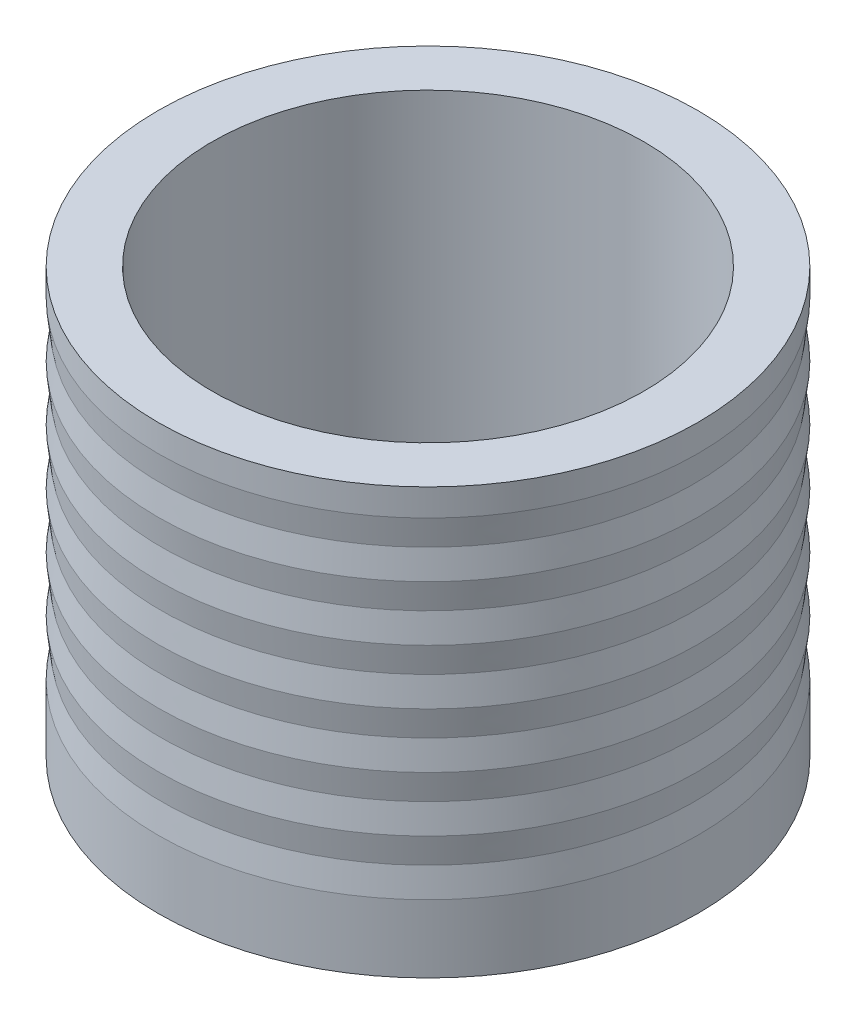
from build123d import *

# Parameters (mm, degrees)
SKETCH2_W       = 6.35
SKETCH2_H       = 50.00625
LPATTERN1_COUNT = 6
LPATTERN1_PITCH = 6.477


with BuildPart() as part:
    # Sketch2 → Revolve1 (revolve)
    with BuildSketch(Plane.XY):
        with Locations((28.575, 25.003125)):
            Rectangle(SKETCH2_W, SKETCH2_H)
    revolve(axis=Axis((0, -40.656569806, 0), (0, 1, 0)))

    # Sketch3 → Cut-Revolve1 (revolve, cut)
    with BuildSketch(Plane.XY):
        Polygon((31.75, 46.83125), (31.369, 43.59275), (31.75, 40.35425), align=None)
    cut_revolve1 = revolve(axis=Axis((0, -40.656569806, 0), (0, 1, 0)), mode=Mode.SUBTRACT)

    # LPattern1: Cut-Revolve1 ×6
    with Locations(*[(0, -i * LPATTERN1_PITCH, 0) for i in range(1, LPATTERN1_COUNT)]):
        add(cut_revolve1, mode=Mode.SUBTRACT)


solid = part.part
